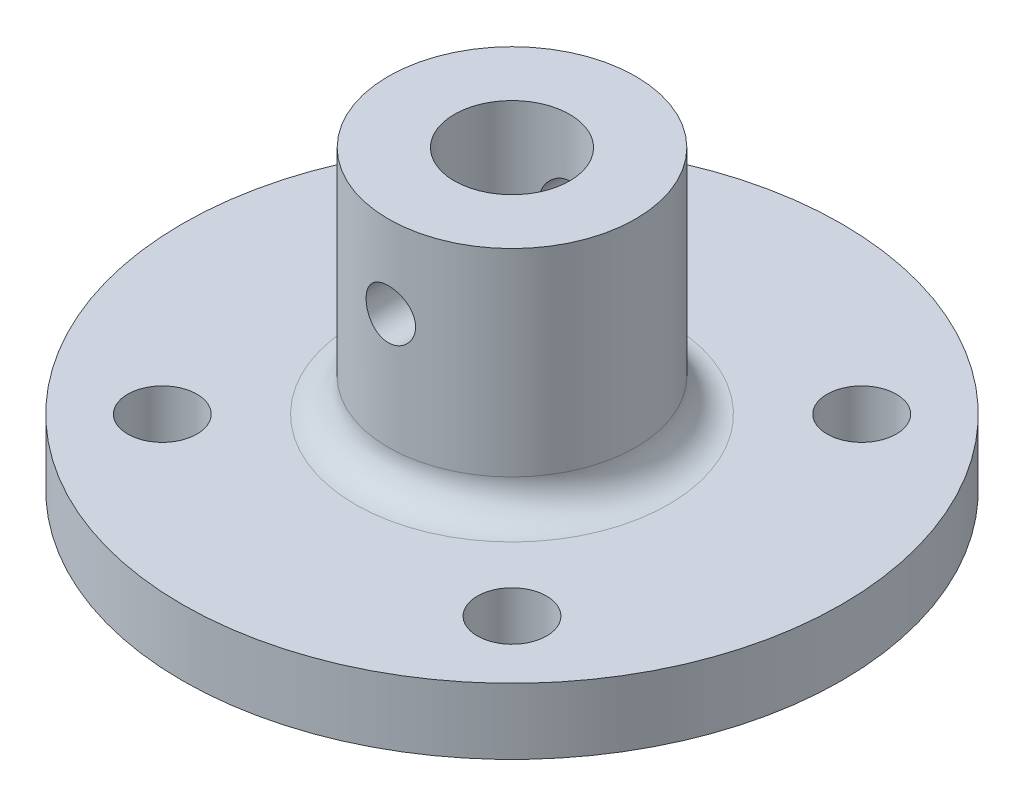
from build123d import *

# Parameters (mm, degrees)
SKETCH1_R               = 20
BOSS_EXTRUDE1_DEPTH     = 4
SKETCH2_R               = 7.5
BOSS_EXTRUDE2_DEPTH     = 14
SKETCH3_R               = 3.5
CUT_EXTRUDE1_DEPTH      = 14
SKETCH5_R               = 1.5
CUT_EXTRUDE2_DEPTH      = 21
CUT_EXTRUDE2_DEPTH_BACK = 21
FILLET1_R               = 2
SKETCH6_R               = 2.1
CUT_EXTRUDE3_DEPTH      = 5


with BuildPart() as part:
    # Sketch1 → Boss-Extrude1 (new body)
    with BuildSketch(Plane(origin=(0, 0, 0), x_dir=(1, 0, 0), z_dir=(0, 1, 0))):
        Circle(SKETCH1_R)
    extrude(amount=BOSS_EXTRUDE1_DEPTH)

    # Sketch2 → Boss-Extrude2 (add)
    with BuildSketch(Plane(origin=(0, 4, 0), x_dir=(1, 0, 0), z_dir=(0, 1, 0))):
        Circle(SKETCH2_R)
    extrude(amount=BOSS_EXTRUDE2_DEPTH)

    # Sketch3 → Cut-Extrude1 (cut)
    with BuildSketch(Plane(origin=(0, 18, 0), x_dir=(1, 0, 0), z_dir=(0, 1, 0))):
        Circle(SKETCH3_R)
    extrude(amount=-CUT_EXTRUDE1_DEPTH, mode=Mode.SUBTRACT)

    # Sketch5 → Cut-Extrude2 (cut, two sides)
    with BuildSketch(Plane.XY) as cut_extrude2_sk:
        with Locations((0, 13)):
            Circle(SKETCH5_R)
    extrude(amount=CUT_EXTRUDE2_DEPTH, mode=Mode.SUBTRACT)
    extrude(cut_extrude2_sk.sketch, amount=-CUT_EXTRUDE2_DEPTH_BACK, mode=Mode.SUBTRACT)

    # Fillet1
    fillet1_edges = [part.edges().sort_by_distance(p)[0] for p in [
        (-7.5, 4, 0),
    ]]
    fillet(fillet1_edges, radius=FILLET1_R)

    # Sketch6 → Cut-Extrude3 (cut, through all)
    with BuildSketch(Plane(origin=(0, 4, 0), x_dir=(1, 0, 0), z_dir=(0, 1, 0))):
        with Locations((10.606601718, 10.606601718)):
            Circle(SKETCH6_R)
        with Locations((-10.606601718, 10.606601718)):
            Circle(SKETCH6_R)
        with Locations((-10.606601718, -10.606601718)):
            Circle(SKETCH6_R)
        with Locations((10.606601718, -10.606601718)):
            Circle(SKETCH6_R)
    extrude(amount=-CUT_EXTRUDE3_DEPTH, mode=Mode.SUBTRACT)


solid = part.part
